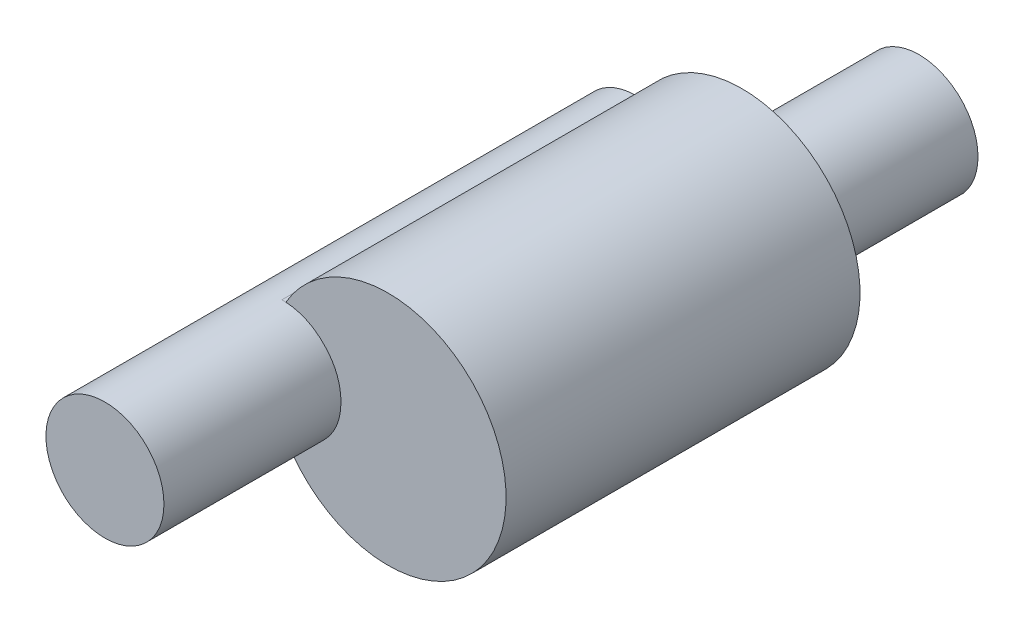
from build123d import *

# Parameters (mm, degrees)
BOSS_EXTRUDE1_DEPTH = 6
SKETCH2_R           = 1
BOSS_EXTRUDE2_DEPTH = 3
SKETCH3_R           = 1
BOSS_EXTRUDE3_DEPTH = 3


with BuildPart() as part:
    # Sketch1 → Boss-Extrude1 (new body)
    with BuildSketch(Plane.XY):
        with BuildLine():
            Line((-6.834228044, 8.847888353), (-6.766278852, 8.847888353))
            ThreePointArc((-6.766278852, 8.847888353), (-3.034228044, 7.847888353), (-6.766278852, 6.847888353))
            Line((-6.766278852, 6.847888353), (-6.834228044, 6.847888353))
            ThreePointArc((-6.834228044, 6.847888353), (-7.834228044, 7.847888353), (-6.834228044, 8.847888353))
        make_face()
    extrude(amount=BOSS_EXTRUDE1_DEPTH)

    # Sketch2 → Boss-Extrude2 (add)
    with BuildSketch(Plane.XY.offset(6)):
        with Locations(Location((-6.834228044, 7.847888353, 0), (0, 0, 270))):
            Circle(SKETCH2_R)
    extrude(amount=BOSS_EXTRUDE2_DEPTH)

    # Sketch3 → Boss-Extrude3 (add)
    with BuildSketch(Plane(origin=(0, 0, 0), x_dir=(-1, 0, 0), z_dir=(0, 0, -1))):
        with Locations(Location((5.034228044, 7.847888353, 0), (0, 0, 180))):
            Circle(SKETCH3_R)
    extrude(amount=BOSS_EXTRUDE3_DEPTH)


solid = part.part
